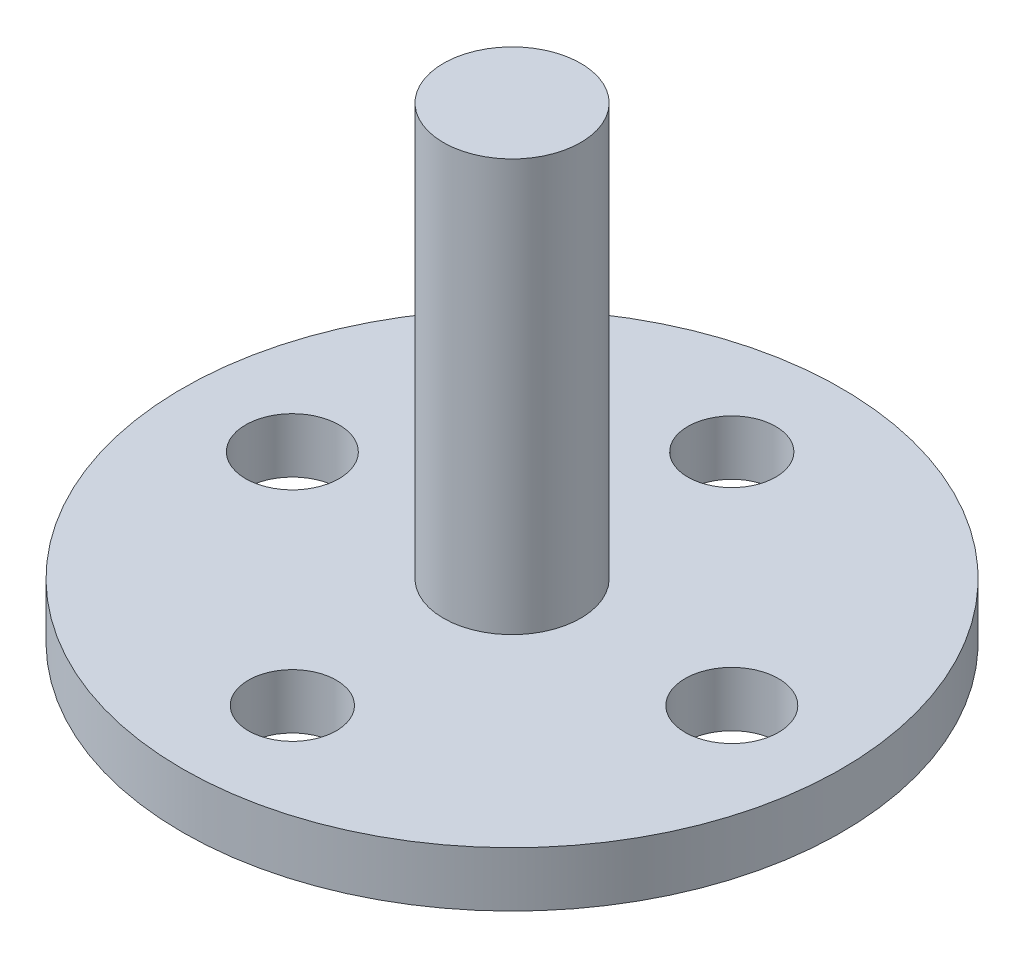
from build123d import *

# Parameters (mm, degrees)
SKETCH_1_R      = 12
SKETCH_1_R_2    = 1.7
SKETCH_1_R_3    = 1.6
EXTRUDE_1_DEPTH = 2
SKETCH_2_R      = 2.5
EXTRUDE_2_DEPTH = 15


with BuildPart() as part:
    # 草图1 → 凸台-拉伸1 (new body)
    with BuildSketch(Plane(origin=(0, 0, 0), x_dir=(1, 0, 0), z_dir=(0, 1, 0))):
        Circle(SKETCH_1_R)
        with Locations((-8, 0)):
            Circle(SKETCH_1_R_2, mode=Mode.SUBTRACT)
        with Locations((0, 8)):
            Circle(SKETCH_1_R_3, mode=Mode.SUBTRACT)
        with Locations((8, 0)):
            Circle(SKETCH_1_R_2, mode=Mode.SUBTRACT)
        with Locations((0, -8)):
            Circle(SKETCH_1_R_3, mode=Mode.SUBTRACT)
    extrude(amount=EXTRUDE_1_DEPTH)

    # 草图2 → 凸台-拉伸2 (add)
    with BuildSketch(Plane(origin=(0, 2, 0), x_dir=(1, 0, 0), z_dir=(0, 1, 0))):
        Circle(SKETCH_2_R)
    extrude(amount=EXTRUDE_2_DEPTH)


solid = part.part
